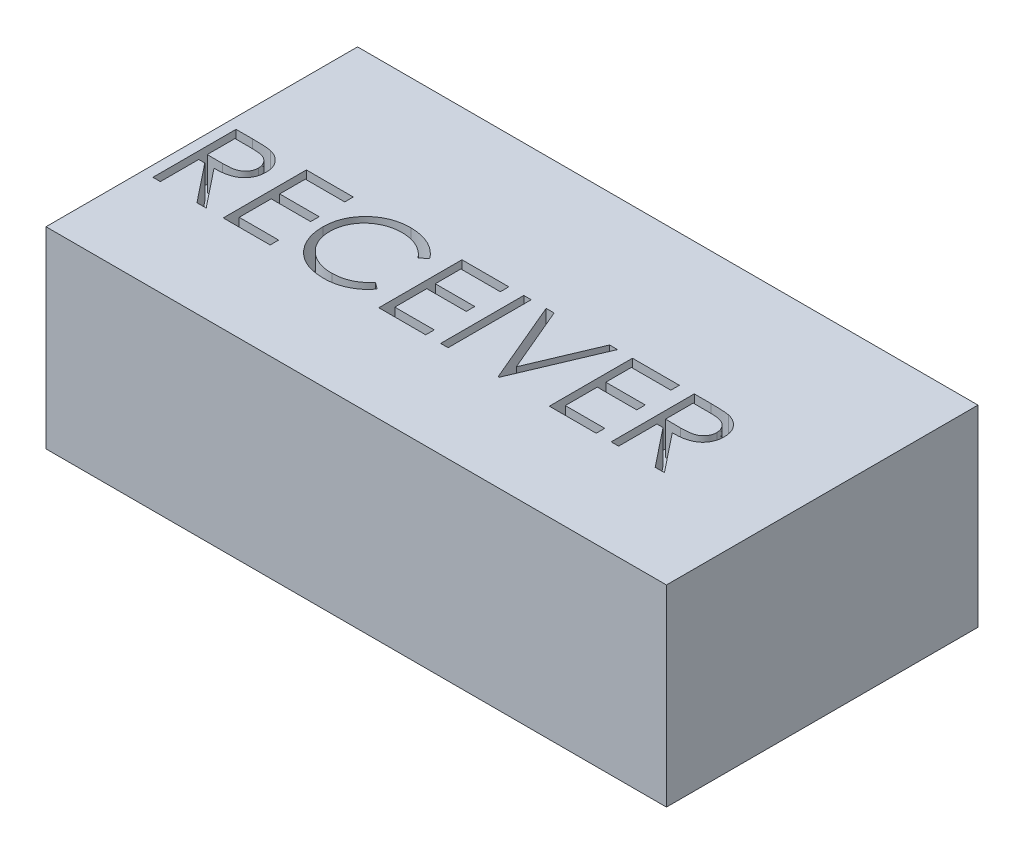
from build123d import *

# Parameters (mm, degrees)
SKETCH1_W           = 47.4
SKETCH1_H           = 23.8
BOSS_EXTRUDE1_DEPTH = 14.7
SKETCH2_W           = 0.569871795
SKETCH2_H           = 6.35
CUT_EXTRUDE1_DEPTH  = 2.54


with BuildPart() as part:
    # Sketch1 → Boss-Extrude1 (new body)
    with BuildSketch(Plane(origin=(0, 0, 0), x_dir=(1, 0, 0), z_dir=(0, 1, 0))):
        Rectangle(SKETCH1_W, SKETCH1_H)
    extrude(amount=BOSS_EXTRUDE1_DEPTH)

    # Sketch2 → Cut-Extrude1 (cut)
    with BuildSketch(Plane(origin=(0, 14.7, 0), x_dir=(1, 0, 0), z_dir=(0, 1, 0))):
        with BuildLine():
            Line((-22.885897436, 1.803083105), (-21.615134215, 1.803083105))
            add(Edge.make_bspline(
                [(-21.615134215, 1.803083105), (-21.530332453, 1.802800827), (-21.367503677, 1.802258824), (-21.134235029, 1.799236654), (-20.922277296, 1.790574608), (-20.731741302, 1.783120464), (-20.562630542, 1.769527942), (-20.414426457, 1.756536482), (-20.287811635, 1.739529983), (-20.21116559, 1.723735859), (-20.17646234, 1.716584707)],
                knots=[0, 0, 0, 0, 0.00025441, 0.000488496, 0.000699792, 0.000890805, 0.001060463, 0.001208681, 0.001337125, 0.001443399, 0.001443399, 0.001443399, 0.001443399], degree=3))
            add(Edge.make_bspline(
                [(-20.17646234, 1.716584707), (-20.130004607, 1.705106147), (-20.038080212, 1.682393896), (-19.90572795, 1.63438862), (-19.779609105, 1.578835873), (-19.660247566, 1.513587409), (-19.548241202, 1.43815888), (-19.442435124, 1.353852429), (-19.342349212, 1.261129356), (-19.252031111, 1.157651858), (-19.166870261, 1.049091333), (-19.095045181, 0.931700232), (-19.033129996, 0.808942889), (-18.983834916, 0.679570859), (-18.944142021, 0.544838788), (-18.916154415, 0.403526256), (-18.899370118, 0.256277059), (-18.897661322, 0.155841996), (-18.896794872, 0.104916038)],
                knots=[0, 0, 0, 0, 0.000143475, 0.00028389, 0.000421699, 0.000556618, 0.000691388, 0.000826278, 0.000962172, 0.001100027, 0.001237925, 0.001375593, 0.001512122, 0.001649843, 0.001790326, 0.001933021, 0.002081501, 0.00223423, 0.00223423, 0.00223423, 0.00223423], degree=3))
            add(Edge.make_bspline(
                [(-18.896794872, 0.104916038), (-18.899460054, 0.020306634), (-18.904660515, -0.144788228), (-18.953147489, -0.384384399), (-19.032570603, -0.607885012), (-19.142014285, -0.815008656), (-19.281386762, -1.001717969), (-19.448890312, -1.165712081), (-19.644618378, -1.302944494), (-19.826825851, -1.398108868), (-19.987778757, -1.459056002), (-20.120282053, -1.501939111), (-20.264820712, -1.535071533), (-20.420009876, -1.564753487), (-20.586495365, -1.587162989), (-20.763878151, -1.603576096), (-20.95228474, -1.613834156), (-21.081714195, -1.615361794), (-21.148297276, -1.616147664)],
                knots=[0, 0, 0, 0, 0.000253595, 0.000494829, 0.000729794, 0.000963101, 0.001194867, 0.001426045, 0.001663231, 0.001909576, 0.002040447, 0.002179239, 0.002327025, 0.002484947, 0.002653149, 0.002830734, 0.00301927, 0.003219016, 0.003219016, 0.003219016, 0.003219016], degree=3))
            Line((-21.148297276, -1.616147664), (-18.815384615, -4.546916895))
            Line((-18.815384615, -4.546916895), (-19.520092147, -4.546916895))
            Line((-19.520092147, -4.546916895), (-21.853004808, -1.616147664))
            Line((-21.853004808, -1.616147664), (-22.316025641, -1.616147664))
            Line((-22.316025641, -1.616147664), (-22.316025641, -4.546916895))
            Line((-22.316025641, -4.546916895), (-22.885897436, -4.546916895))
            Line((-22.885897436, -4.546916895), (-22.885897436, 1.803083105))
        make_face()
        with BuildLine():
            Line((-22.316025641, 1.151801054), (-22.316025641, -0.964865613))
            Line((-22.316025641, -0.964865613), (-21.153385417, -0.97376986))
            add(Edge.make_bspline(
                [(-21.153385417, -0.97376986), (-21.099101917, -0.973793875), (-20.993885035, -0.973840423), (-20.841665258, -0.966594572), (-20.699933055, -0.958351694), (-20.569230548, -0.945743596), (-20.449499347, -0.929494723), (-20.340799297, -0.909169309), (-20.24295296, -0.885489138), (-20.12883704, -0.848837617), (-20.001407905, -0.790769555), (-19.862920828, -0.706286436), (-19.744988015, -0.60002532), (-19.645351322, -0.478516335), (-19.565287925, -0.344919141), (-19.508841769, -0.200835157), (-19.473023338, -0.049901829), (-19.468798691, 0.053835595), (-19.466666667, 0.106188073)],
                knots=[0, 0, 0, 0, 0.000162825, 0.000315602, 0.000457079, 0.000588714, 0.000709424, 0.000819445, 0.00092033, 0.001011243, 0.00117863, 0.001339219, 0.001495984, 0.001652341, 0.001809194, 0.001961079, 0.002115058, 0.002271936, 0.002271936, 0.002271936, 0.002271936], degree=3))
            add(Edge.make_bspline(
                [(-19.466666667, 0.106188073), (-19.468847658, 0.157253999), (-19.473169586, 0.258448033), (-19.508455209, 0.406595184), (-19.568125944, 0.546416651), (-19.648539147, 0.677343645), (-19.746509043, 0.796189766), (-19.861385646, 0.897875315), (-19.990027928, 0.981785058), (-20.110262817, 1.035405148), (-20.217730602, 1.068279739), (-20.3110387, 1.091413993), (-20.416469524, 1.110000387), (-20.534534998, 1.124892155), (-20.6647311, 1.137691839), (-20.807716138, 1.146312923), (-20.96254144, 1.151418077), (-21.069850872, 1.151670424), (-21.125400641, 1.151801054)],
                knots=[0, 0, 0, 0, 0.000153073, 0.000303335, 0.000453828, 0.000607413, 0.000762788, 0.000914166, 0.00106588, 0.0012219, 0.001307193, 0.001402833, 0.001510122, 0.00162814, 0.001759776, 0.001902522, 0.002057794, 0.002224435, 0.002224435, 0.002224435, 0.002224435], degree=3))
            Line((-21.125400641, 1.151801054), (-22.316025641, 1.151801054))
        make_face(mode=Mode.SUBTRACT)
        Polygon((-17.512820513, 1.803083105), (-13.930769231, 1.803083105), (-13.930769231, 1.151801054), (-16.942948718, 1.151801054), (-16.942948718, -0.8020451), (-13.930769231, -0.8020451), (-13.930769231, -1.453327152), (-16.942948718, -1.453327152), (-16.942948718, -3.895634844), (-13.930769231, -3.895634844), (-13.930769231, -4.546916895), (-17.512820513, -4.546916895), align=None)
        with BuildLine():
            Line((-6.929487179, 0.63789881), (-7.428125, 0.256288233))
            add(Edge.make_bspline(
                [(-7.428125, 0.256288233), (-7.463695683, 0.298680778), (-7.53435748, 0.382894325), (-7.648039176, 0.501148642), (-7.766515013, 0.611938473), (-7.889739705, 0.715791598), (-8.01993125, 0.809076301), (-8.153935842, 0.896653874), (-8.293995153, 0.975153913), (-8.4876733, 1.070336759), (-8.741034396, 1.169661926), (-9.059976461, 1.252943503), (-9.392918025, 1.305959064), (-9.620062242, 1.311700991), (-9.735596955, 1.314621566)],
                knots=[0, 0, 0, 0, 0.00016598, 0.000329722, 0.000491716, 0.000652466, 0.000812762, 0.000971889, 0.001132508, 0.001294072, 0.001619108, 0.001946783, 0.002281403, 0.002627792, 0.002627792, 0.002627792, 0.002627792], degree=3))
            add(Edge.make_bspline(
                [(-9.735596955, 1.314621566), (-9.799248084, 1.313888663), (-9.925959599, 1.312429658), (-10.114007544, 1.293181674), (-10.298544079, 1.266128479), (-10.479449168, 1.225986821), (-10.656492536, 1.175236498), (-10.830831608, 1.114593247), (-10.999942268, 1.039563751), (-11.166163928, 0.956635908), (-11.325420497, 0.862968973), (-11.476106084, 0.760800463), (-11.617671111, 0.651273674), (-11.750227565, 0.533978095), (-11.873910957, 0.409441967), (-11.987825078, 0.27633809), (-12.091575751, 0.135092004), (-12.187219496, -0.01243375), (-12.272876884, -0.165809458), (-12.344595379, -0.3256028), (-12.408104672, -0.489077387), (-12.458359013, -0.658080207), (-12.49813635, -0.831422082), (-12.525582254, -1.009568226), (-12.544611337, -1.192146473), (-12.546063087, -1.315897655), (-12.546794872, -1.378277071)],
                knots=[0, 0, 0, 0, 0.000190873, 0.000379975, 0.000566531, 0.000750171, 0.000935383, 0.001118838, 0.001303406, 0.001489997, 0.001675871, 0.001857215, 0.00203583, 0.002212456, 0.002387854, 0.002561974, 0.002737519, 0.002913231, 0.003089167, 0.003263923, 0.003438266, 0.003614933, 0.003792367, 0.00397138, 0.004155417, 0.004342476, 0.004342476, 0.004342476, 0.004342476], degree=3))
            add(Edge.make_bspline(
                [(-12.546794872, -1.378277071), (-12.544505572, -1.472132466), (-12.540010834, -1.656405084), (-12.500008857, -1.926317478), (-12.439221048, -2.1848907), (-12.348115644, -2.430508414), (-12.235776795, -2.666199292), (-12.093825972, -2.887975498), (-11.929421683, -3.099188408), (-11.740238093, -3.294846327), (-11.532673255, -3.473578372), (-11.309973473, -3.630968712), (-11.072693408, -3.762168571), (-10.82345295, -3.871344931), (-10.560334144, -3.955267851), (-10.283810145, -4.014348475), (-9.994482382, -4.05288786), (-9.796780757, -4.056577551), (-9.696163862, -4.058455357)],
                knots=[0, 0, 0, 0, 0.000281407, 0.000552506, 0.000816909, 0.001076865, 0.001336862, 0.001598716, 0.001865134, 0.002138624, 0.00241374, 0.002685831, 0.002955172, 0.00322576, 0.003500919, 0.003782108, 0.004073207, 0.004374897, 0.004374897, 0.004374897, 0.004374897], degree=3))
            add(Edge.make_bspline(
                [(-9.696163862, -4.058455357), (-9.585306126, -4.055391428), (-9.367111583, -4.049360882), (-9.047129592, -3.998271959), (-8.740813275, -3.915435451), (-8.448146154, -3.799506363), (-8.169953295, -3.648802198), (-7.905799355, -3.466107478), (-7.655461362, -3.24968436), (-7.50492775, -3.084433541), (-7.428125, -3.000122023)],
                knots=[0, 0, 0, 0, 0.000332413, 0.000654268, 0.000969327, 0.00128278, 0.001596377, 0.00191641, 0.002244649, 0.002586564, 0.002586564, 0.002586564, 0.002586564], degree=3))
            Line((-7.428125, -3.000122023), (-6.929487179, -3.377916494))
            add(Edge.make_bspline(
                [(-6.929487179, -3.377916494), (-6.96961575, -3.4296934), (-7.049680678, -3.532999203), (-7.179325938, -3.678635019), (-7.315900463, -3.815620912), (-7.46041868, -3.942852453), (-7.611218102, -4.062875555), (-7.77100644, -4.172280306), (-7.937683113, -4.272593768), (-8.110683382, -4.364445474), (-8.289823436, -4.445938193), (-8.474888626, -4.515704315), (-8.665081241, -4.575802329), (-8.860409978, -4.625245128), (-9.061279994, -4.663836952), (-9.266966425, -4.689635505), (-9.477913199, -4.707310121), (-9.620228349, -4.708921054), (-9.692347756, -4.709737408)],
                knots=[0, 0, 0, 0, 0.000196475, 0.000392009, 0.000584494, 0.000776437, 0.000969338, 0.001162339, 0.001356932, 0.001552676, 0.001749645, 0.001946913, 0.002145652, 0.002347729, 0.002551052, 0.002758846, 0.002969382, 0.003185688, 0.003185688, 0.003185688, 0.003185688], degree=3))
            add(Edge.make_bspline(
                [(-9.692347756, -4.709737408), (-9.760644124, -4.709262079), (-9.895691733, -4.708322174), (-10.095079468, -4.693096384), (-10.289189136, -4.67232329), (-10.477465957, -4.641044767), (-10.660937369, -4.604134321), (-10.837940144, -4.55465647), (-11.010216026, -4.499231553), (-11.177072872, -4.434089649), (-11.338652613, -4.360581718), (-11.4944341, -4.277502746), (-11.644345684, -4.185551363), (-11.789861233, -4.086754416), (-11.928831135, -3.977938454), (-12.062459674, -3.860614703), (-12.191496167, -3.735178597), (-12.271329609, -3.644727649), (-12.311468349, -3.599250629)],
                knots=[0, 0, 0, 0, 0.000204833, 0.000405032, 0.000599587, 0.000790308, 0.000977414, 0.001160715, 0.00134133, 0.00152015, 0.001697748, 0.001873588, 0.002049424, 0.00222513, 0.002400957, 0.002578537, 0.002758439, 0.002940353, 0.002940353, 0.002940353, 0.002940353], degree=3))
            add(Edge.make_bspline(
                [(-12.311468349, -3.599250629), (-12.375758731, -3.520254472), (-12.503563325, -3.363215869), (-12.667077065, -3.108697017), (-12.807044772, -2.842961838), (-12.920212514, -2.564614253), (-13.008682044, -2.274278851), (-13.069970784, -1.971809274), (-13.109797266, -1.657488008), (-13.114351648, -1.443698406), (-13.116666667, -1.335027873)],
                knots=[0, 0, 0, 0, 0.000305355, 0.000607023, 0.000905735, 0.001205258, 0.001507055, 0.001814903, 0.002130142, 0.002456031, 0.002456031, 0.002456031, 0.002456031], degree=3))
            add(Edge.make_bspline(
                [(-13.116666667, -1.335027873), (-13.113845101, -1.220808693), (-13.108293847, -0.996089587), (-13.061130047, -0.6662997), (-12.985258802, -0.350339305), (-12.877495876, -0.048798225), (-12.740870453, 0.239909569), (-12.572093596, 0.513578612), (-12.373126067, 0.773959091), (-12.145528337, 1.01710014), (-11.895941886, 1.239421537), (-11.628663466, 1.435012792), (-11.34421622, 1.597786), (-11.045733832, 1.733850466), (-10.730981238, 1.838433992), (-10.400629983, 1.911646202), (-10.055300809, 1.957215827), (-9.819693265, 1.962976562), (-9.699979968, 1.965903618)],
                knots=[0, 0, 0, 0, 0.000342518, 0.000673882, 0.000997212, 0.001315861, 0.001632785, 0.001953703, 0.002278593, 0.002614297, 0.002951278, 0.003280008, 0.003605977, 0.003932749, 0.004262596, 0.004598972, 0.004946556, 0.005305595, 0.005305595, 0.005305595, 0.005305595], degree=3))
            add(Edge.make_bspline(
                [(-9.699979968, 1.965903618), (-9.627019426, 1.965028881), (-9.482601381, 1.963297429), (-9.268964426, 1.946413428), (-9.06097049, 1.918267314), (-8.85847628, 1.87995673), (-8.660496676, 1.832409161), (-8.46854481, 1.770468905), (-8.281494336, 1.699645484), (-8.100524945, 1.618077982), (-7.926504918, 1.526516894), (-7.759488455, 1.42597712), (-7.600802211, 1.316583301), (-7.449329586, 1.199265826), (-7.30760446, 1.071542725), (-7.171602921, 0.936927087), (-7.045943536, 0.791541435), (-6.968377025, 0.689206769), (-6.929487179, 0.63789881)],
                knots=[0, 0, 0, 0, 0.000218849, 0.00043319, 0.000642412, 0.000848234, 0.001051238, 0.001252787, 0.001452885, 0.001651012, 0.001847882, 0.002042474, 0.002235476, 0.002425806, 0.002616797, 0.002807484, 0.002999544, 0.003192664, 0.003192664, 0.003192664, 0.003192664], degree=3))
        make_face()
        Polygon((-5.626923077, 1.803083105), (-2.044871795, 1.803083105), (-2.044871795, 1.151801054), (-5.057051282, 1.151801054), (-5.057051282, -0.8020451), (-2.044871795, -0.8020451), (-2.044871795, -1.453327152), (-5.057051282, -1.453327152), (-5.057051282, -3.895634844), (-2.044871795, -3.895634844), (-2.044871795, -4.546916895), (-5.626923077, -4.546916895), align=None)
        with Locations((-0.620192307, -1.371916895)):
            Rectangle(SKETCH2_W, SKETCH2_H)
        Polygon((0.804487179, 1.803083105), (1.415064103, 1.803083105), (3.531730769, -3.201103594), (5.648397436, 1.803083105), (6.258974359, 1.803083105), (3.572435897, -4.546916895), (3.491025641, -4.546916895), align=None)
        Polygon((7.398717949, 1.803083105), (10.980769231, 1.803083105), (10.980769231, 1.151801054), (7.968589744, 1.151801054), (7.968589744, -0.8020451), (10.980769231, -0.8020451), (10.980769231, -1.453327152), (7.968589744, -1.453327152), (7.968589744, -3.895634844), (10.980769231, -3.895634844), (10.980769231, -4.546916895), (7.398717949, -4.546916895), align=None)
        with BuildLine():
            Line((12.120512821, 1.803083105), (13.391276042, 1.803083105))
            add(Edge.make_bspline(
                [(13.391276042, 1.803083105), (13.476077803, 1.802800827), (13.63890658, 1.802258824), (13.872175227, 1.799236654), (14.08413296, 1.790574608), (14.274668955, 1.783120464), (14.443779714, 1.769527942), (14.591983799, 1.756536482), (14.718598622, 1.739529983), (14.795244666, 1.723735859), (14.829947917, 1.716584707)],
                knots=[0, 0, 0, 0, 0.00025441, 0.000488496, 0.000699792, 0.000890805, 0.001060463, 0.001208681, 0.001337125, 0.001443399, 0.001443399, 0.001443399, 0.001443399], degree=3))
            add(Edge.make_bspline(
                [(14.829947917, 1.716584707), (14.876405649, 1.705106147), (14.968330044, 1.682393896), (15.100682307, 1.63438862), (15.226801152, 1.578835873), (15.34616269, 1.513587409), (15.458169054, 1.43815888), (15.563975132, 1.353852429), (15.664061044, 1.261129356), (15.754379145, 1.157651858), (15.839539996, 1.049091333), (15.911365075, 0.931700232), (15.97328026, 0.808942889), (16.022575341, 0.679570859), (16.062268236, 0.544838788), (16.090255841, 0.403526256), (16.107040139, 0.256277059), (16.108748934, 0.155841996), (16.109615385, 0.104916038)],
                knots=[0, 0, 0, 0, 0.000143475, 0.00028389, 0.000421699, 0.000556618, 0.000691388, 0.000826278, 0.000962172, 0.001100027, 0.001237925, 0.001375593, 0.001512122, 0.001649843, 0.001790326, 0.001933021, 0.002081501, 0.00223423, 0.00223423, 0.00223423, 0.00223423], degree=3))
            add(Edge.make_bspline(
                [(16.109615385, 0.104916038), (16.106950202, 0.020306634), (16.101749741, -0.144788228), (16.053262768, -0.384384399), (15.973839653, -0.607885012), (15.864395972, -0.815008656), (15.725023494, -1.001717969), (15.557519945, -1.165712081), (15.361791878, -1.302944494), (15.179584405, -1.398108868), (15.0186315, -1.459056002), (14.886128204, -1.501939111), (14.741589545, -1.535071533), (14.58640038, -1.564753487), (14.419914891, -1.587162989), (14.242532105, -1.603576096), (14.054125516, -1.613834156), (13.924696062, -1.615361794), (13.858112981, -1.616147664)],
                knots=[0, 0, 0, 0, 0.000253595, 0.000494829, 0.000729794, 0.000963101, 0.001194867, 0.001426045, 0.001663231, 0.001909576, 0.002040447, 0.002179239, 0.002327025, 0.002484947, 0.002653149, 0.002830734, 0.00301927, 0.003219016, 0.003219016, 0.003219016, 0.003219016], degree=3))
            Line((13.858112981, -1.616147664), (16.191025641, -4.546916895))
            Line((16.191025641, -4.546916895), (15.486318109, -4.546916895))
            Line((15.486318109, -4.546916895), (13.153405449, -1.616147664))
            Line((13.153405449, -1.616147664), (12.690384615, -1.616147664))
            Line((12.690384615, -1.616147664), (12.690384615, -4.546916895))
            Line((12.690384615, -4.546916895), (12.120512821, -4.546916895))
            Line((12.120512821, -4.546916895), (12.120512821, 1.803083105))
        make_face()
        with BuildLine():
            Line((12.690384615, 1.151801054), (12.690384615, -0.964865613))
            Line((12.690384615, -0.964865613), (13.85302484, -0.97376986))
            add(Edge.make_bspline(
                [(13.85302484, -0.97376986), (13.907308339, -0.973793875), (14.012525221, -0.973840423), (14.164744999, -0.966594572), (14.306477201, -0.958351694), (14.437179709, -0.945743596), (14.55691091, -0.929494723), (14.66561096, -0.909169309), (14.763457297, -0.885489138), (14.877573216, -0.848837617), (15.005002352, -0.790769555), (15.143489429, -0.706286436), (15.261422242, -0.60002532), (15.361058935, -0.478516335), (15.441122332, -0.344919141), (15.497568488, -0.200835157), (15.533386919, -0.049901829), (15.537611565, 0.053835595), (15.53974359, 0.106188073)],
                knots=[0, 0, 0, 0, 0.000162825, 0.000315602, 0.000457079, 0.000588714, 0.000709424, 0.000819445, 0.00092033, 0.001011243, 0.00117863, 0.001339219, 0.001495984, 0.001652341, 0.001809194, 0.001961079, 0.002115058, 0.002271936, 0.002271936, 0.002271936, 0.002271936], degree=3))
            add(Edge.make_bspline(
                [(15.53974359, 0.106188073), (15.537562599, 0.157253999), (15.53324067, 0.258448033), (15.497955047, 0.406595184), (15.438284312, 0.546416651), (15.357871109, 0.677343645), (15.259901214, 0.796189766), (15.145024611, 0.897875315), (15.016382328, 0.981785058), (14.89614744, 1.035405148), (14.788679654, 1.068279739), (14.695371557, 1.091413993), (14.589940733, 1.110000387), (14.471875258, 1.124892155), (14.341679156, 1.137691839), (14.198694118, 1.146312923), (14.043868817, 1.151418077), (13.936559384, 1.151670424), (13.881009615, 1.151801054)],
                knots=[0, 0, 0, 0, 0.000153073, 0.000303335, 0.000453828, 0.000607413, 0.000762788, 0.000914166, 0.00106588, 0.0012219, 0.001307193, 0.001402833, 0.001510122, 0.00162814, 0.001759776, 0.001902522, 0.002057794, 0.002224435, 0.002224435, 0.002224435, 0.002224435], degree=3))
            Line((13.881009615, 1.151801054), (12.690384615, 1.151801054))
        make_face(mode=Mode.SUBTRACT)
    extrude(amount=-CUT_EXTRUDE1_DEPTH, mode=Mode.SUBTRACT)


solid = part.part
